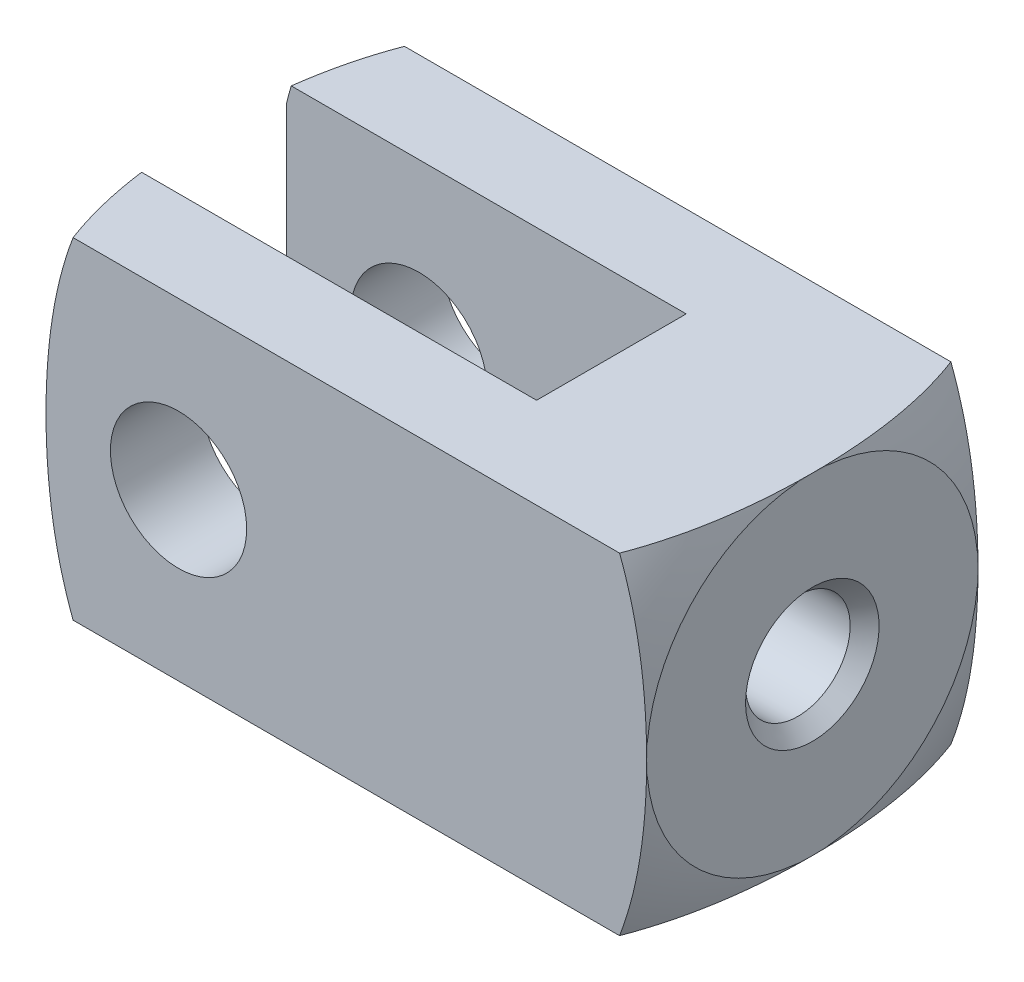
from build123d import *

# Parameters (mm, degrees)
BOSS_EXTRUDE1_DEPTH      = 3.937
BOSS_EXTRUDE1_DEPTH_BACK = 3.937
SKETCH1_W                = 14.2748
SKETCH1_H                = 7.874
CUT_EXTRUDE1_DEPTH       = 3.937
CUT_EXTRUDE1_DEPTH_BACK  = 3.937
SKETCH2_W                = 9.4996
SKETCH2_H                = 3.556
SKETCH4_W                = 0.2032
SKETCH4_H                = 1.26365
SKETCH5_W                = 7.874
SKETCH5_H                = 1.61925


with BuildPart() as part:
    # Sketch1 → Boss-Extrude1 (new, two sides: drawn at the far end of the back side and taken through both)
    with BuildSketch(Plane.XY.offset(-BOSS_EXTRUDE1_DEPTH_BACK)):
        with Locations((3.9878, 0)):
            Rectangle(SKETCH1_W, SKETCH1_H)
    extrude(amount=BOSS_EXTRUDE1_DEPTH + BOSS_EXTRUDE1_DEPTH_BACK)

    # Sketch2 → Cut-Extrude1 (cut, two sides: drawn at the far end of the back side and taken through both)
    with BuildSketch(Plane(origin=(0, 0, 0), x_dir=(1, 0, 0), z_dir=(0, 1, 0)).offset(-CUT_EXTRUDE1_DEPTH_BACK)):
        with Locations((1.6002, 0)):
            Rectangle(SKETCH2_W, SKETCH2_H)
    extrude(amount=CUT_EXTRUDE1_DEPTH + CUT_EXTRUDE1_DEPTH_BACK, mode=Mode.SUBTRACT)

    # Sketch3 → Cut-Revolve1 (revolve, cut)
    with BuildSketch(Plane.XY):
        Polygon((6.5532, 0), (6.5532, 1.24333), (10.78103, 1.24333), (11.1252, 1.5875), (11.1252, 0), align=None)
    revolve(axis=Axis((11.1252, 0, 0), (-1, 0, 0)), mode=Mode.SUBTRACT)

    # Sketch4 → Cut-Revolve2 (revolve, cut)
    with BuildSketch(Plane.XY):
        with Locations((6.4516, 0.631825)):
            Rectangle(SKETCH4_W, SKETCH4_H)
    revolve(axis=Axis((6.5532, 0, 0), (-1, 0, 0)), mode=Mode.SUBTRACT)

    # Sketch5 → Cut-Revolve3 (revolve, cut)
    with BuildSketch(Plane(origin=(0, 0, 0), x_dir=(0, 0, -1), z_dir=(1, 0, 0))):
        with Locations((0, 0.809625)):
            Rectangle(SKETCH5_W, SKETCH5_H)
    revolve(axis=Axis((0, 0, -3.937), (0, 0, 1)), mode=Mode.SUBTRACT)

    # Sketch6 → Cut-Revolve4 (revolve, cut)
    with BuildSketch(Plane.XY):
        with BuildLine():
            Line((11.1252, 0), (11.1252, 3.937))
            ThreePointArc((11.1252, 3.937), (10.164844056, 6.105270359), (8.5852, 7.874))
            Line((8.5852, 7.874), (15.0622, 7.874))
            Line((15.0622, 7.874), (15.0622, 0))
            Line((15.0622, 0), (11.1252, 0))
        make_face()
    revolve(axis=Axis((15.0622, 0, 0), (-1, 0, 0)), mode=Mode.SUBTRACT)

    # Sketch7 → Cut-Revolve5 (revolve, cut)
    with BuildSketch(Plane.XY):
        with BuildLine():
            Line((-7.0866, 0), (-7.0866, 7.874))
            Line((-7.0866, 7.874), (-0.6096, 7.874))
            ThreePointArc((-0.6096, 7.874), (-2.189244056, 6.105270359), (-3.1496, 3.937))
            Line((-3.1496, 3.937), (-3.1496, 0))
            Line((-3.1496, 0), (-7.0866, 0))
        make_face()
    revolve(axis=Axis((-3.1496, 0, 0), (-1, 0, 0)), mode=Mode.SUBTRACT)


solid = part.part
